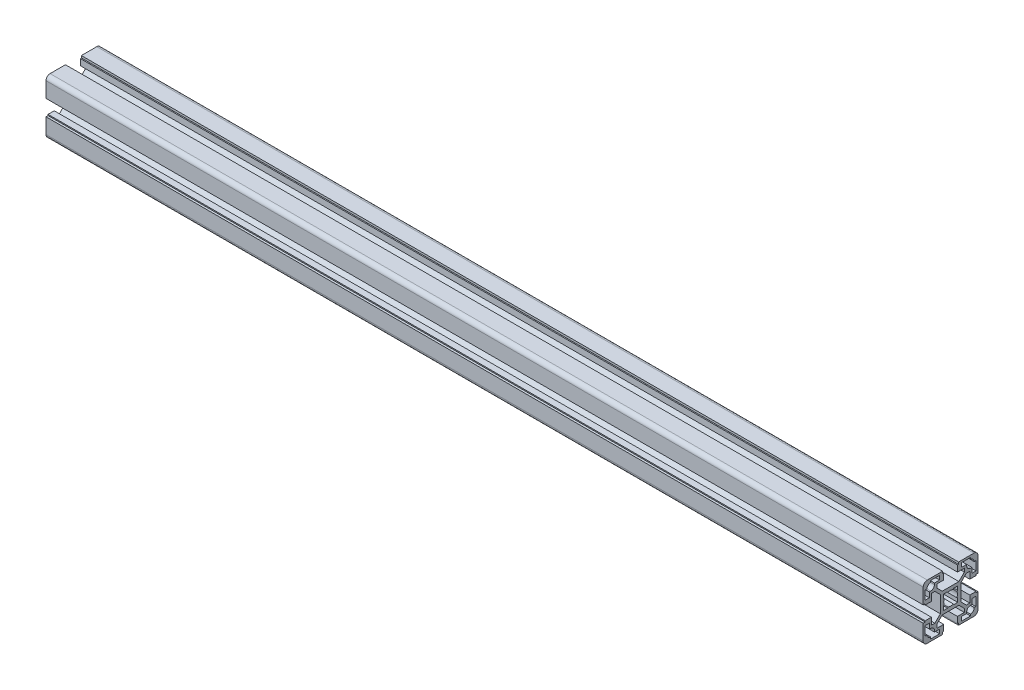
from build123d import *

# Parameters (mm, degrees)
BR_EXTRUDE_DEPTH      = 320
BR_EXTRUDE_DEPTH_BACK = 320


with BuildPart() as part:
    # Sketch2 → BR_Extrude (new body, two sides)
    with BuildSketch(Plane(origin=(0, 0, 0), x_dir=(0, 0, -1), z_dir=(1, 0, 0))) as br_extrude_sk:
        with BuildLine():
            Line((-10.05, 11.464213562), (-10.05, 14))
            Line((-10.05, 14), (-5, 14))
            Line((-5, 14), (-5, 18.5))
            Line((-5, 18.5), (-5.8, 18.5))
            Line((-5.8, 18.5), (-5.8, 20))
            Line((-5.8, 20), (-17, 20))
            ThreePointArc((-17, 20), (-19.121320344, 19.121320344), (-20, 17))
            Line((-20, 17), (-20, 5.8))
            Line((-20, 5.8), (-18.5, 5.8))
            Line((-18.5, 5.8), (-18.5, 5))
            Line((-18.5, 5), (-14, 5))
            Line((-14, 5), (-14, 10.05))
            Line((-14, 10.05), (-11.464213562, 10.05))
            Line((-11.464213562, 10.05), (-7.5, 6.085786438))
            Line((-7.5, 6.085786438), (-7.5, -6.085786438))
            Line((-7.5, -6.085786438), (-11.464213562, -10.05))
            Line((-11.464213562, -10.05), (-14, -10.05))
            Line((-14, -10.05), (-14, -5))
            Line((-14, -5), (-18.5, -5))
            Line((-18.5, -5), (-18.5, -5.8))
            Line((-18.5, -5.8), (-20, -5.8))
            Line((-20, -5.8), (-20, -17))
            ThreePointArc((-20, -17), (-19.121320344, -19.121320344), (-17, -20))
            Line((-17, -20), (-5.8, -20))
            Line((-5.8, -20), (-5.8, -18.5))
            Line((-5.8, -18.5), (-5, -18.5))
            Line((-5, -18.5), (-5, -14))
            Line((-5, -14), (-10.05, -14))
            Line((-10.05, -14), (-10.05, -11.464213562))
            Line((-10.05, -11.464213562), (-6.085786438, -7.5))
            Line((-6.085786438, -7.5), (6.085786438, -7.5))
            Line((6.085786438, -7.5), (10.05, -11.464213562))
            Line((10.05, -11.464213562), (10.05, -14))
            Line((10.05, -14), (5, -14))
            Line((5, -14), (5, -18.5))
            Line((5, -18.5), (5.8, -18.5))
            Line((5.8, -18.5), (5.8, -20))
            Line((5.8, -20), (17, -20))
            ThreePointArc((17, -20), (19.121320344, -19.121320344), (20, -17))
            Line((20, -17), (20, -5.8))
            Line((20, -5.8), (18.5, -5.8))
            Line((18.5, -5.8), (18.5, -5))
            Line((18.5, -5), (14, -5))
            Line((14, -5), (14, -10.05))
            Line((14, -10.05), (11.464213562, -10.05))
            Line((11.464213562, -10.05), (7.5, -6.085786438))
            Line((7.5, -6.085786438), (7.5, 6.085786438))
            Line((7.5, 6.085786438), (11.464213562, 10.05))
            Line((11.464213562, 10.05), (14, 10.05))
            Line((14, 10.05), (14, 5))
            Line((14, 5), (18.5, 5))
            Line((18.5, 5), (18.5, 5.8))
            Line((18.5, 5.8), (20, 5.8))
            Line((20, 5.8), (20, 17))
            ThreePointArc((20, 17), (19.121320344, 19.121320344), (17, 20))
            Line((17, 20), (5.8, 20))
            Line((5.8, 20), (5.8, 18.5))
            Line((5.8, 18.5), (5, 18.5))
            Line((5, 18.5), (5, 14))
            Line((5, 14), (10.05, 14))
            Line((10.05, 14), (10.05, 11.464213562))
            Line((10.05, 11.464213562), (6.085786438, 7.5))
            Line((6.085786438, 7.5), (-6.085786438, 7.5))
            Line((-6.085786438, 7.5), (-10.05, 11.464213562))
        make_face()
        with BuildLine():
            Line((8, 15.5), (8, 18.5))
            Line((8, 18.5), (14.5, 18.5))
            Line((14.5, 18.5), (14.5, 17.25))
            ThreePointArc((14.5, 17.25), (16.444543648, 16.444543648), (17.25, 14.5))
            Line((17.25, 14.5), (18.5, 14.5))
            Line((18.5, 14.5), (18.5, 8))
            Line((18.5, 8), (15.5, 8))
            Line((15.5, 8), (15.5, 11.75))
            Line((15.5, 11.75), (14.5, 11.75))
            ThreePointArc((14.5, 11.75), (12.555456352, 12.555456352), (11.75, 14.5))
            Line((11.75, 14.5), (11.75, 15.5))
            Line((11.75, 15.5), (8, 15.5))
        make_face(mode=Mode.SUBTRACT)
        with BuildLine():
            Line((8, -15.5), (11.75, -15.5))
            Line((11.75, -15.5), (11.75, -14.5))
            ThreePointArc((11.75, -14.5), (12.555456352, -12.555456352), (14.5, -11.75))
            Line((14.5, -11.75), (15.5, -11.75))
            Line((15.5, -11.75), (15.5, -8))
            Line((15.5, -8), (18.5, -8))
            Line((18.5, -8), (18.5, -14.5))
            Line((18.5, -14.5), (17.25, -14.5))
            ThreePointArc((17.25, -14.5), (16.444543648, -16.444543648), (14.5, -17.25))
            Line((14.5, -17.25), (14.5, -18.5))
            Line((14.5, -18.5), (8, -18.5))
            Line((8, -18.5), (8, -15.5))
        make_face(mode=Mode.SUBTRACT)
        with BuildLine():
            Line((-15.5, 8), (-18.5, 8))
            Line((-18.5, 8), (-18.5, 14.5))
            Line((-18.5, 14.5), (-17.25, 14.5))
            ThreePointArc((-17.25, 14.5), (-16.444543648, 16.444543648), (-14.5, 17.25))
            Line((-14.5, 17.25), (-14.5, 18.5))
            Line((-14.5, 18.5), (-8, 18.5))
            Line((-8, 18.5), (-8, 15.5))
            Line((-8, 15.5), (-11.75, 15.5))
            Line((-11.75, 15.5), (-11.75, 14.5))
            ThreePointArc((-11.75, 14.5), (-12.555456352, 12.555456352), (-14.5, 11.75))
            Line((-14.5, 11.75), (-15.5, 11.75))
            Line((-15.5, 11.75), (-15.5, 8))
        make_face(mode=Mode.SUBTRACT)
        with BuildLine():
            Line((-11.75, -14.5), (-11.75, -15.5))
            Line((-11.75, -15.5), (-8, -15.5))
            Line((-8, -15.5), (-8, -18.5))
            Line((-8, -18.5), (-14.5, -18.5))
            Line((-14.5, -18.5), (-14.5, -17.25))
            ThreePointArc((-14.5, -17.25), (-16.444543648, -16.444543648), (-17.25, -14.5))
            Line((-17.25, -14.5), (-18.5, -14.5))
            Line((-18.5, -14.5), (-18.5, -8))
            Line((-18.5, -8), (-15.5, -8))
            Line((-15.5, -8), (-15.5, -11.75))
            Line((-15.5, -11.75), (-14.5, -11.75))
            ThreePointArc((-14.5, -11.75), (-12.555456352, -12.555456352), (-11.75, -14.5))
        make_face(mode=Mode.SUBTRACT)
        with BuildLine():
            Line((-5.2, -5.2), (-5.2, -2.26102435))
            Line((-5.2, -2.26102435), (-4.585300372, -1.993745345))
            ThreePointArc((-4.585300372, -1.993745345), (-5, 0), (-4.585300372, 1.993745345))
            Line((-4.585300372, 1.993745345), (-5.2, 2.26102435))
            Line((-5.2, 2.26102435), (-5.2, 5.2))
            Line((-5.2, 5.2), (-2.26102435, 5.2))
            Line((-2.26102435, 5.2), (-1.993745345, 4.585300372))
            ThreePointArc((-1.993745345, 4.585300372), (0, 5), (1.993745345, 4.585300372))
            Line((1.993745345, 4.585300372), (2.26102435, 5.2))
            Line((2.26102435, 5.2), (5.2, 5.2))
            Line((5.2, 5.2), (5.2, 2.26102435))
            Line((5.2, 2.26102435), (4.585300372, 1.993745345))
            ThreePointArc((4.585300372, 1.993745345), (5, 0), (4.585300372, -1.993745345))
            Line((4.585300372, -1.993745345), (5.2, -2.26102435))
            Line((5.2, -2.26102435), (5.2, -5.2))
            Line((5.2, -5.2), (2.26102435, -5.2))
            Line((2.26102435, -5.2), (1.993745345, -4.585300372))
            ThreePointArc((1.993745345, -4.585300372), (0, -5), (-1.993745345, -4.585300372))
            Line((-1.993745345, -4.585300372), (-2.26102435, -5.2))
            Line((-2.26102435, -5.2), (-5.2, -5.2))
        make_face(mode=Mode.SUBTRACT)
    extrude(amount=BR_EXTRUDE_DEPTH)
    extrude(br_extrude_sk.sketch, amount=-BR_EXTRUDE_DEPTH_BACK)


solid = part.part
